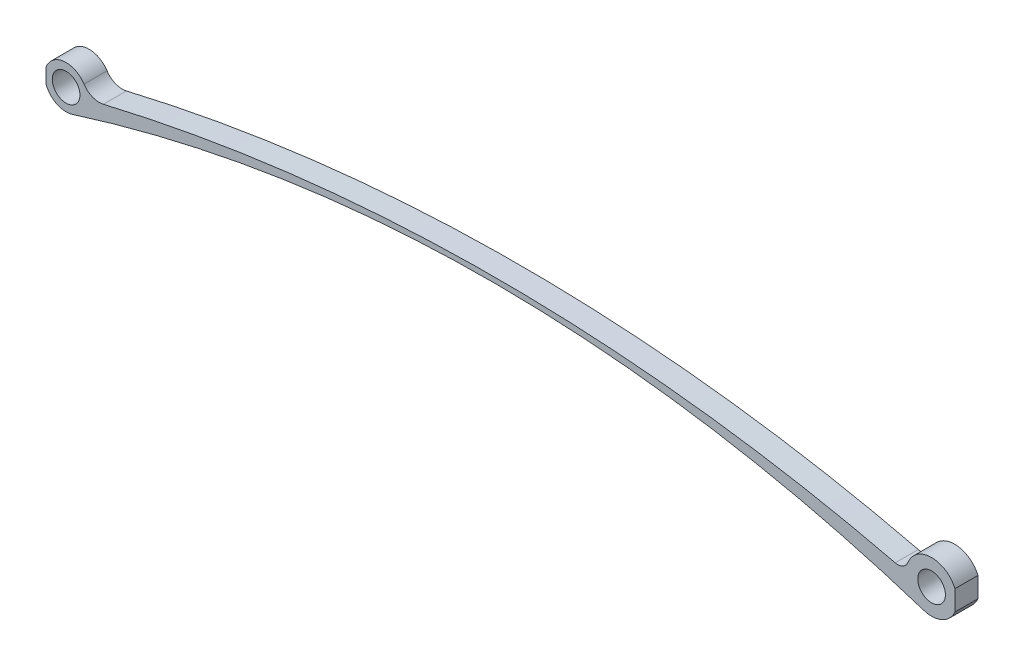
from build123d import *

# Parameters (mm, degrees)
SZKIC1_R                    = 3.000000079
DODANIE_WYCI_GNI_CIE1_DEPTH = 5
SZKIC2_W                    = 1.618528634
SZKIC2_H                    = 7.505645785
SZKIC2_W_2                  = 0.651830256
SZKIC2_H_2                  = 5.051684483
WYTNIJ_WYCI_GNI_CIE3_DEPTH  = 6


with BuildPart() as part:
    # Szkic1 → Dodanie-wyciągnięcie1 (new body)
    with BuildSketch(Plane.XY):
        with BuildLine():
            ThreePointArc((186.045988776, -5.249251796), (192.755281751, 2.359338104), (182.617163035, 2.007483882))
            ThreePointArc((182.617163035, 2.007483882), (181.515461762, 0.778054457), (179.877075261, 0.575737672))
            ThreePointArc((179.877075261, 0.575737672), (94.000924782, 10.812852228), (8.093986869, 0.837394654))
            ThreePointArc((8.093986869, 0.837394654), (5.723921358, 1.013693466), (3.888246839, 2.523193668))
            ThreePointArc((3.888246839, 2.523193668), (-4.36345679, 1.5637182), (1.40056399, -4.418528067))
            ThreePointArc((1.40056399, -4.418528067), (93.788487806, 9.660689232), (186.045988776, -5.249251796))
        make_face()
        Circle(SZKIC1_R, mode=Mode.SUBTRACT)
        with Locations((187.762, 0)):
            Circle(SZKIC1_R, mode=Mode.SUBTRACT)
    extrude(amount=DODANIE_WYCI_GNI_CIE1_DEPTH)

    # Szkic2 → Wytnij-wyciągnięcie3 (cut, through all)
    with BuildSketch(Plane.XY):
        with Locations((193.638606269, 0.381285041)):
            Rectangle(SZKIC2_W, SZKIC2_H)
        with Locations((-4.682734605, -0.038745932)):
            Rectangle(SZKIC2_W_2, SZKIC2_H_2)
    extrude(amount=WYTNIJ_WYCI_GNI_CIE3_DEPTH, mode=Mode.SUBTRACT)


solid = part.part
